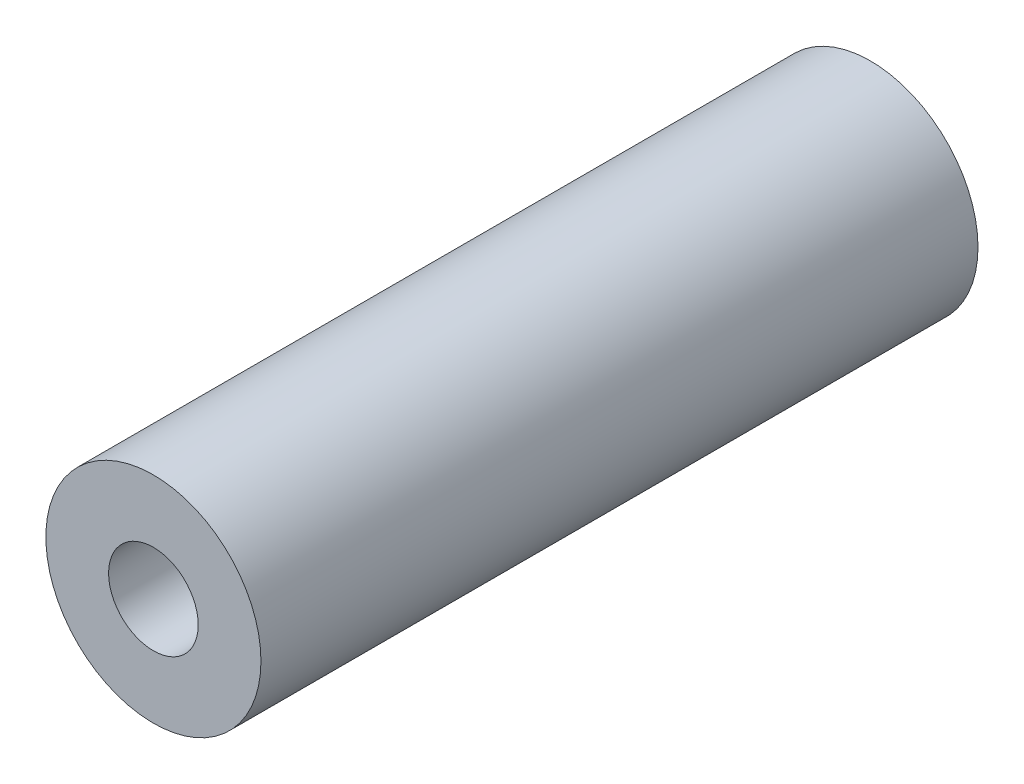
from build123d import *

# Parameters (mm, degrees)
SKETCH_1_R               = 3
EXTRUDE_1_DEPTH          = 10
M3X0_5_1_D               = 2.5
M3X0_5_1_DEPTH           = 6.5
M3X0_5_1_TIP             = 0.751075774
M3X0_5_1_ON_FACE_2_D     = 2.5
M3X0_5_1_ON_FACE_2_DEPTH = 6.5
M3X0_5_1_ON_FACE_2_TIP   = 0.751075774
SKETCH_3_R               = 1.25
CUT_EXTRUDE_1_DEPTH      = 20


with BuildPart() as part:
    # ｽｹｯﾁ1 → ﾎﾞｽ - 押し出し1 (new body, symmetric)
    with BuildSketch(Plane.XY):
        Circle(SKETCH_1_R)
    extrude(amount=EXTRUDE_1_DEPTH, both=True)

    # M3x0.5 ねじ穴1
    with Locations(Plane.XY.offset(10)):
        with Locations((0, 0)):
            Hole(M3X0_5_1_D / 2, depth=M3X0_5_1_DEPTH)
            with Locations((0, 0, -(M3X0_5_1_DEPTH + M3X0_5_1_TIP / 2))):  # 118° drill point
                Cone(0, M3X0_5_1_D / 2, M3X0_5_1_TIP, mode=Mode.SUBTRACT)

    # M3x0.5 ねじ穴1 on face 2
    with Locations(Plane(origin=(0, 0, -10), x_dir=(-1, 0, 0), z_dir=(0, 0, -1))):
        with Locations((0, 0)):
            Hole(M3X0_5_1_ON_FACE_2_D / 2, depth=M3X0_5_1_ON_FACE_2_DEPTH)
            with Locations((0, 0, -(M3X0_5_1_ON_FACE_2_DEPTH + M3X0_5_1_ON_FACE_2_TIP / 2))):  # 118° drill point
                Cone(0, M3X0_5_1_ON_FACE_2_D / 2, M3X0_5_1_ON_FACE_2_TIP, mode=Mode.SUBTRACT)

    # ｽｹｯﾁ3 → ｶｯﾄ - 押し出し1 (cut)
    with BuildSketch(Plane(origin=(0, 0, -10), x_dir=(-1, 0, 0), z_dir=(0, 0, -1))):
        Circle(SKETCH_3_R)
    extrude(amount=-CUT_EXTRUDE_1_DEPTH, mode=Mode.SUBTRACT)


solid = part.part
